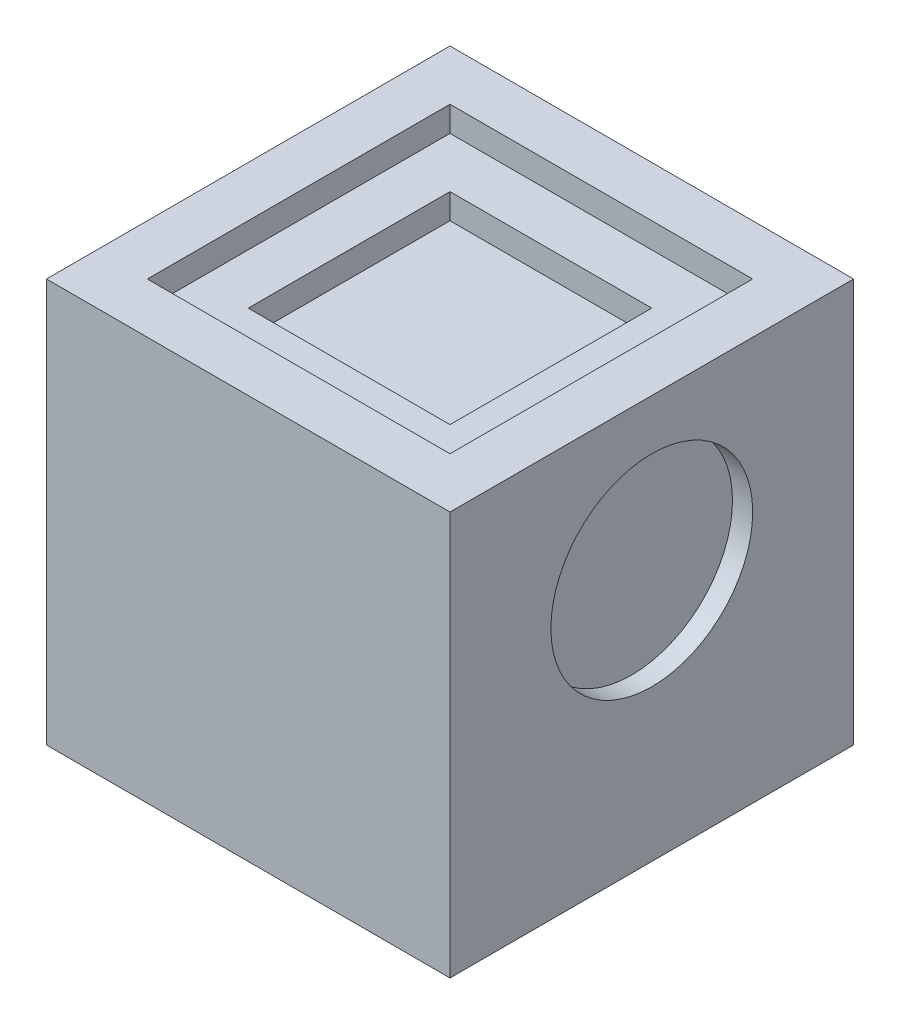
from build123d import *

# Parameters (mm, degrees)
SKETCH1_W           = 50.8
SKETCH1_H           = 50.8
BOSS_EXTRUDE1_DEPTH = 50.8
SKETCH4_R           = 12.7
CUT_EXTRUDE3_DEPTH  = 2.54
SKETCH5_W           = 38.1
SKETCH5_H           = 38.1
CUT_EXTRUDE5_DEPTH  = 3.175
SKETCH6_W           = 25.4
SKETCH6_H           = 25.4
CUT_EXTRUDE6_DEPTH  = 3.175


with BuildPart() as part:
    # Sketch1 → Boss-Extrude1 (new body)
    with BuildSketch(Plane(origin=(0, 0, 0), x_dir=(1, 0, 0), z_dir=(0, 1, 0))):
        Rectangle(SKETCH1_W, SKETCH1_H)
    extrude(amount=BOSS_EXTRUDE1_DEPTH)

    # Sketch4 → Cut-Extrude3 (cut)
    with BuildSketch(Plane(origin=(25.4, 0, 0), x_dir=(0, 0, -1), z_dir=(1, 0, 0))):
        with Locations((0, 31.75)):
            Circle(SKETCH4_R)
    extrude(amount=-CUT_EXTRUDE3_DEPTH, mode=Mode.SUBTRACT)

    # Sketch5 → Cut-Extrude5 (cut)
    with BuildSketch(Plane(origin=(0, 50.8, 0), x_dir=(1, 0, 0), z_dir=(0, 1, 0))):
        Rectangle(SKETCH5_W, SKETCH5_H)
    extrude(amount=-CUT_EXTRUDE5_DEPTH, mode=Mode.SUBTRACT)

    # Sketch6 → Cut-Extrude6 (cut)
    with BuildSketch(Plane(origin=(0, 47.625, 0), x_dir=(1, 0, 0), z_dir=(0, 1, 0))):
        Rectangle(SKETCH6_W, SKETCH6_H)
    extrude(amount=-CUT_EXTRUDE6_DEPTH, mode=Mode.SUBTRACT)


solid = part.part
